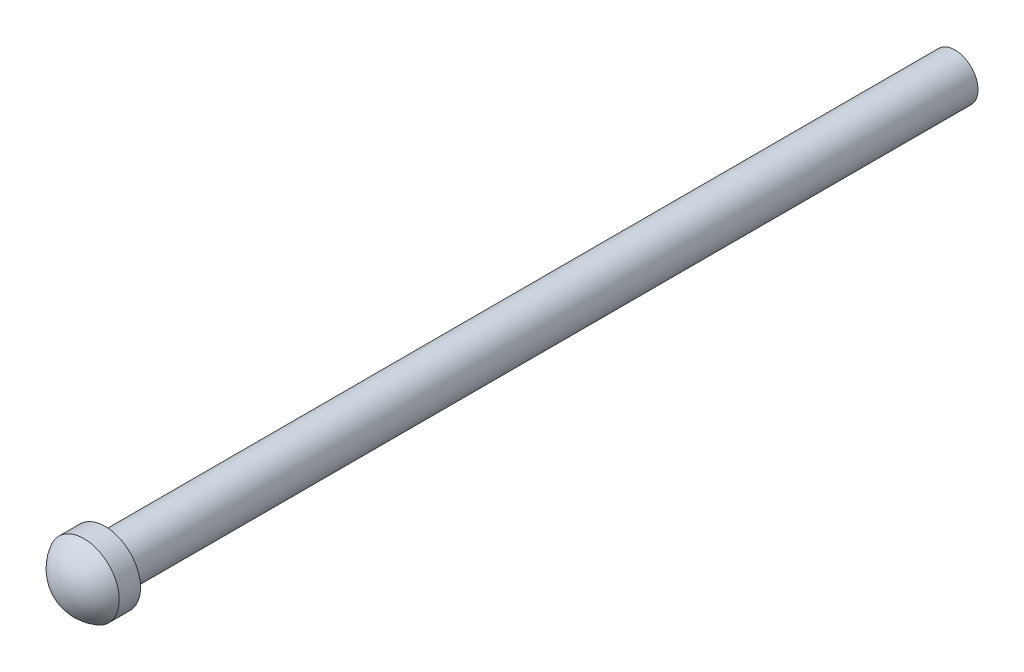
from build123d import *

# Parameters (mm, degrees)
SKETCH1_R           = 3.25
SKETCH3_R           = 5
BOSS_EXTRUDE1_DEPTH = 3
DOME1_FACE_RADIUS   = 5
DOME1_HEIGHT        = 3


with BuildPart() as part:
    # Sweep1: sweep along a path in Sketch2
    with BuildLine(Plane(origin=(5, 0, 0), x_dir=(0, 0, -1), z_dir=(1, 0, 0))) as sweep1_path:
        Line((0, 0), (120, 0))
    # Sketch1 → Sweep1 (sweep)
    with BuildSketch(Plane.XY):
        with Locations((5, 60)):
            Circle(SKETCH1_R)
    sweep(path=sweep1_path.line)

    # Sketch3 → Boss-Extrude1 (add)
    with BuildSketch(Plane.XY):
        with Locations((5, 60)):
            Circle(SKETCH3_R)
    extrude(amount=BOSS_EXTRUDE1_DEPTH)

    # Dome1: a dome of height H over a round flat face of radius A is a cap of a sphere of radius (A * A + H * H) / (2 * H)
    dome1_r = (DOME1_FACE_RADIUS * DOME1_FACE_RADIUS + DOME1_HEIGHT * DOME1_HEIGHT) / (2 * DOME1_HEIGHT)
    dome1_base = Plane((5, 60, 3), z_dir=(0, 0, 1))
    with Locations(dome1_base.offset(DOME1_HEIGHT - dome1_r)):
        dome1_ball = Sphere(dome1_r, mode=Mode.PRIVATE)
    add(split(dome1_ball, bisect_by=dome1_base, keep=Keep.TOP, mode=Mode.PRIVATE))


solid = part.part
